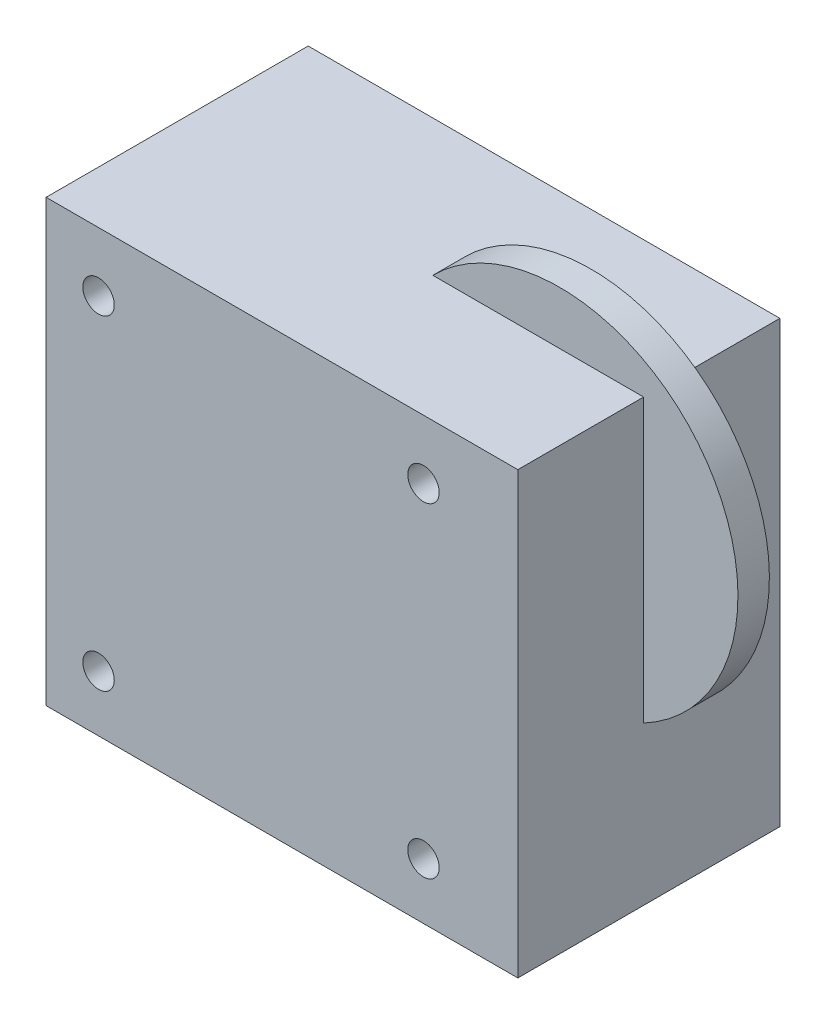
from build123d import *

# Parameters (mm, degrees)
SKETCH1_W           = 45
SKETCH1_H           = 42
BOSS_EXTRUDE1_DEPTH = 25
SKETCH2_R           = 1.5
CUT_EXTRUDE1_DEPTH  = 26
SKETCH3_R           = 17
BOSS_EXTRUDE2_DEPTH = 3


with BuildPart() as part:
    # Sketch1 → Boss-Extrude1 (new body)
    with BuildSketch(Plane.XY):
        Rectangle(SKETCH1_W, SKETCH1_H)
    extrude(amount=BOSS_EXTRUDE1_DEPTH)

    # Sketch2 → Cut-Extrude1 (cut, through all)
    with BuildSketch(Plane.XY.offset(25)):
        with Locations((13.5, 15.35)):
            Circle(SKETCH2_R)
        with Locations((-17.5, 15.35)):
            Circle(SKETCH2_R)
        with Locations((-17.5, -15.65)):
            Circle(SKETCH2_R)
        with Locations((13.5, -15.65)):
            Circle(SKETCH2_R)
    extrude(amount=-CUT_EXTRUDE1_DEPTH, mode=Mode.SUBTRACT)

    # Sketch3 → Boss-Extrude2 (add)
    with BuildSketch(Plane.XY.offset(10)):
        with Locations((14.5, 9.06439174)):
            Circle(SKETCH3_R)
    extrude(amount=BOSS_EXTRUDE2_DEPTH)


solid = part.part
